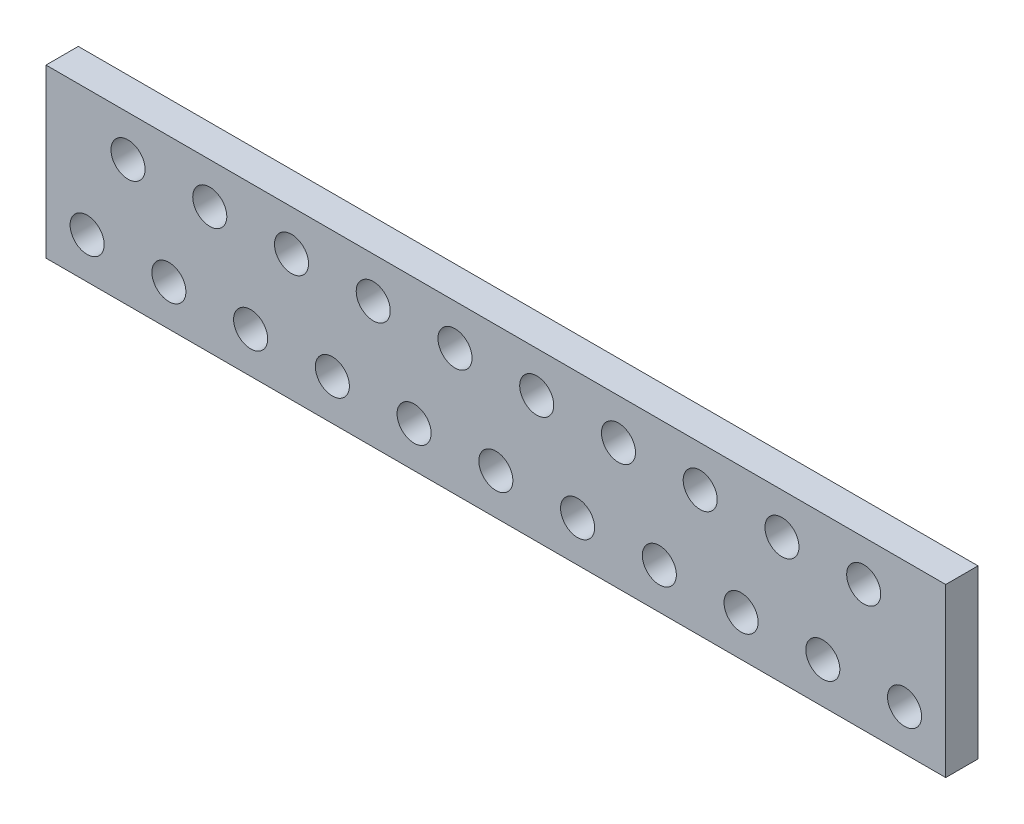
from build123d import *

# Parameters (mm, degrees)
SKETCH1_W          = 39.624
SKETCH1_H          = 7.366
PEEK_DEPTH         = 1.4224
SKETCH2_R          = 0.75
CUT_EXTRUDE1_DEPTH = 2.4224


with BuildPart() as part:
    # Sketch1 → PEEK (new body)
    with BuildSketch(Plane.XY):
        Rectangle(SKETCH1_W, SKETCH1_H)
    extrude(amount=PEEK_DEPTH)

    # Sketch2 → Cut-Extrude1 (cut, through all)
    with BuildSketch(Plane(origin=(0, 0, 0), x_dir=(-1, 0, 0), z_dir=(0, 0, -1))):
        with Locations((-18, -1.885)):
            Circle(SKETCH2_R)
        with Locations((-14.4, -1.885)):
            Circle(SKETCH2_R)
        with Locations((-10.8, -1.885)):
            Circle(SKETCH2_R)
        with Locations((-7.2, -1.885)):
            Circle(SKETCH2_R)
        with Locations((-3.6, -1.885)):
            Circle(SKETCH2_R)
        with Locations((0, -1.885)):
            Circle(SKETCH2_R)
        with Locations((3.6, -1.885)):
            Circle(SKETCH2_R)
        with Locations((7.2, -1.885)):
            Circle(SKETCH2_R)
        with Locations((10.8, -1.885)):
            Circle(SKETCH2_R)
        with Locations((14.4, -1.885)):
            Circle(SKETCH2_R)
        with Locations((18, -1.885)):
            Circle(SKETCH2_R)
        with Locations((16.2, 1.885)):
            Circle(SKETCH2_R)
        with Locations((12.6, 1.885)):
            Circle(SKETCH2_R)
        with Locations((9, 1.885)):
            Circle(SKETCH2_R)
        with Locations((5.4, 1.885)):
            Circle(SKETCH2_R)
        with Locations((1.8, 1.885)):
            Circle(SKETCH2_R)
        with Locations((-1.8, 1.885)):
            Circle(SKETCH2_R)
        with Locations((-5.4, 1.885)):
            Circle(SKETCH2_R)
        with Locations((-9, 1.885)):
            Circle(SKETCH2_R)
        with Locations((-12.6, 1.885)):
            Circle(SKETCH2_R)
        with Locations((-16.2, 1.885)):
            Circle(SKETCH2_R)
    extrude(amount=-CUT_EXTRUDE1_DEPTH, mode=Mode.SUBTRACT)


solid = part.part
